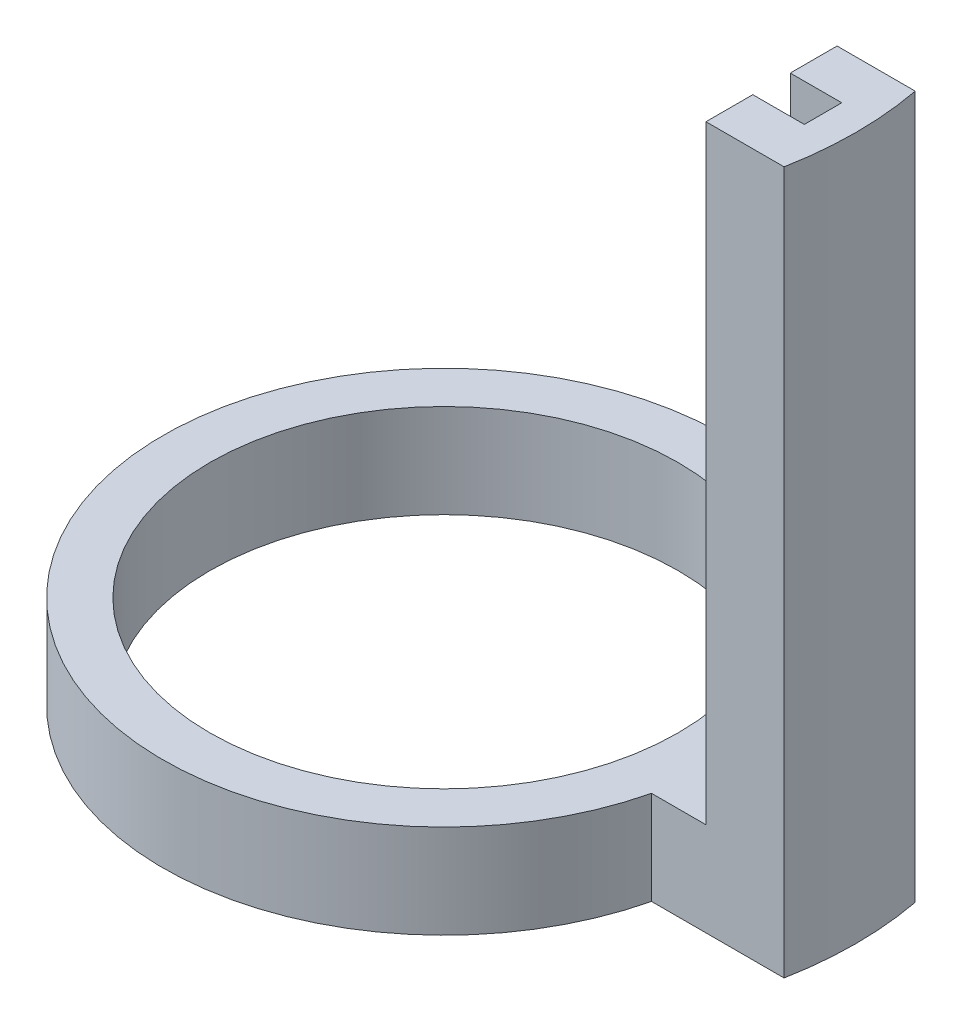
from build123d import *

# Parameters (mm, degrees)
SKETCH1_R           = 50
BOSS_EXTRUDE1_DEPTH = 20
BOSS_EXTRUDE2_DEPTH = 150


with BuildPart() as part:
    # Sketch1 → Boss-Extrude1 (new body)
    with BuildSketch(Plane(origin=(0, 0, 0), x_dir=(1, 0, 0), z_dir=(0, 1, 0))):
        with BuildLine():
            ThreePointArc((50.339164764, 13.978703751), (-68.009745742, 0.022314378), (50.328751088, -14.02210054))
            Line((50.328751088, -14.02210054), (61.947059133, -14.02210054))
            Line((61.947059133, -14.02210054), (61.947059133, 13.978703751))
            Line((61.947059133, 13.978703751), (50.339164764, 13.978703751))
        make_face()
        with Locations((-8.009749891, 0)):
            Circle(SKETCH1_R, mode=Mode.SUBTRACT)
    extrude(amount=BOSS_EXTRUDE1_DEPTH)

    # Sketch1_4 → Boss-Extrude2 (add)
    with BuildSketch(Plane(origin=(0, 0, 0), x_dir=(1, 0, 0), z_dir=(0, 1, 0))):
        with BuildLine():
            Line((72.947059133, 3.978703751), (72.947059133, -4.02210054))
            Line((72.947059133, -4.02210054), (61.947059133, -4.02210054))
            Line((61.947059133, -4.02210054), (61.947059133, -14.02210054))
            Line((61.947059133, -14.02210054), (78.624604535, -14.02210054))
            ThreePointArc((78.624604535, -14.02210054), (79.947055881, -0.022086627), (78.632850446, 13.978703751))
            Line((78.632850446, 13.978703751), (61.947059133, 13.978703751))
            Line((61.947059133, 13.978703751), (61.947059133, 3.978703751))
            Line((61.947059133, 3.978703751), (72.947059133, 3.978703751))
        make_face()
    extrude(amount=BOSS_EXTRUDE2_DEPTH)


solid = part.part
